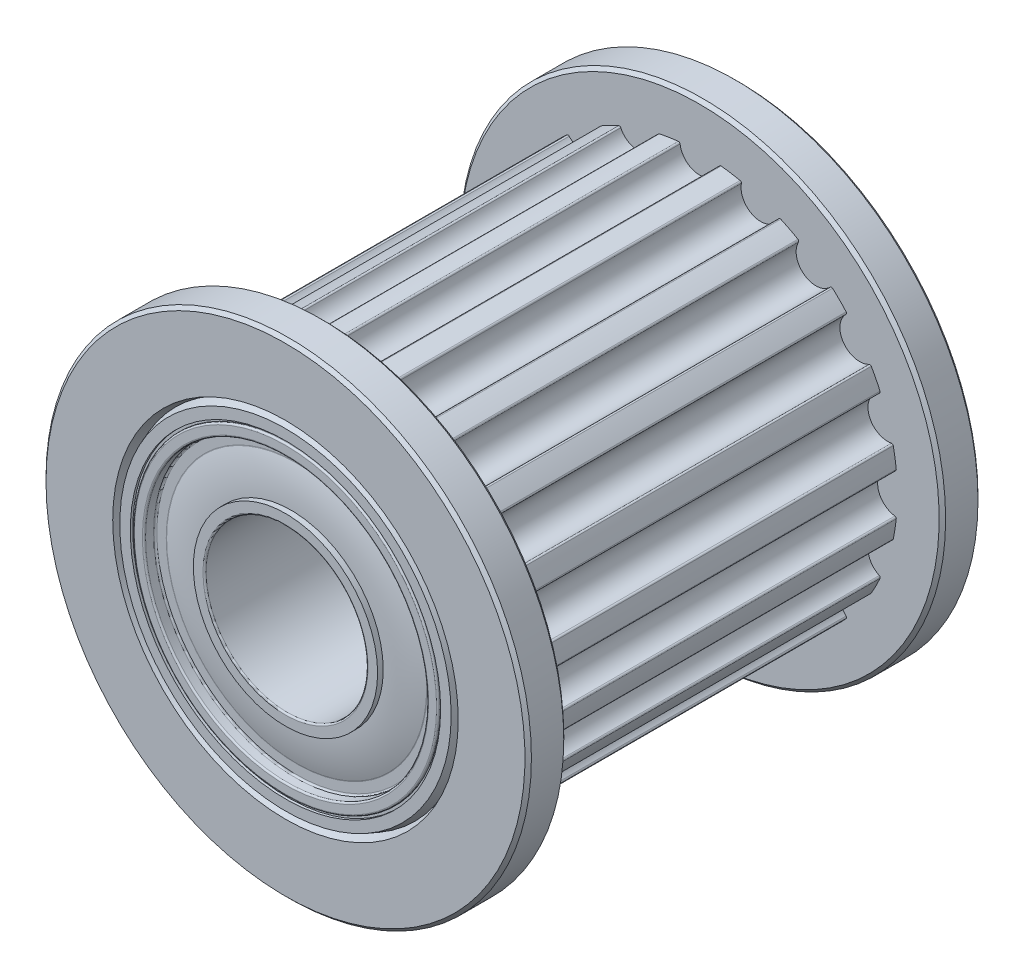
from build123d import *

# Parameters (mm, degrees)
CUT_EXTRUDE1_REACH             = 14.708
CUT_EXTRUDE1_DIRECTION_2_REACH = 14.708
FILLET1_R                      = 0.05
CIRPATTERN3_COUNT              = 20
FILLET1_OF_CIRPATTERN3_R       = 0.05
CHAMFER1_SIZE                  = 0.1
FILLET2_R                      = 0.05


with BuildPart() as part:
    # Sketch2 → Revolve1 (revolve)
    with BuildSketch(Plane(origin=(0, 0, 0), x_dir=(0, 0, -1), z_dir=(1, 0, 0))):
        with BuildLine():
            Line((7, 2.5), (0, 2.5))
            Line((0, 2.5), (0, 4.72))
            Line((0, 4.72), (7, 4.72))
            Line((7, 4.72), (7, 4.3725))
            Line((7, 4.3725), (6.6525, 4.3725))
            Line((6.6525, 4.3725), (6.6525, 4.025))
            ThreePointArc((6.6525, 4.025), (6.782578593, 3.442625053), (6.82625, 2.8475))
            Line((6.82625, 2.8475), (7, 2.8475))
            Line((7, 2.8475), (7, 2.5))
        make_face()
    revolve(axis=Axis((0, 0, 7), (0, 0, -1)))

    # Mirror1: part across plane


with BuildPart() as part_1:
    add(part.part)
    add(part.part.mirror(Plane.XY))

    # Fillet2
    fillet2_edges = [part_1.edges().sort_by_distance(p)[0] for p in [
        (0, -4.025, 6.6525),
        (0, -4.3725, 6.6525),
        (0, -4.72, 7),
        (0, -4.3725, 7),
        (0, -2.5, 7),
        (0, -2.5, -7),
        (0, -4.72, -7),
        (0, -4.025, -6.6525),
        (0, -4.3725, -7),
        (0, -2.8475, -7),
    ]]
    fillet(fillet2_edges, radius=FILLET2_R)


with BuildPart() as body_2:
    # Sketch3 → Revolve2 (revolve)
    with BuildSketch(Plane(origin=(0, 0, 0), x_dir=(0, 0, -1), z_dir=(1, 0, 0))):
        Polygon((5.8, 7.5), (7, 7.5), (7, 5.338382141), (6.7, 5.22919107), (7, 5.12), (7, 4.795), (6.925, 4.795), (6.925, 4.72), (-6.925, 4.72), (-6.925, 4.795), (-7, 4.795), (-7, 5.12), (-6.7, 5.22919107), (-7, 5.338382141), (-7, 7.5), (-5.8, 7.5), (-5.8, 6.11), (5.8, 6.11), align=None)
    revolve(axis=Axis((0, 0, 7), (0, 0, -1)))

    # Cut-Extrude1: up to this face of the body (flat: up to its plane)
    cut_extrude1_end = Plane(body_2.part.faces().sort_by_distance((0, -6.322132034, -5.8))[0])
    # Sketch4 → Cut-Extrude1 (cut, up to the picked face)
    with BuildSketch(Plane.XY, mode=Mode.PRIVATE) as cut_extrude1_sk1:
        with BuildLine():
            Line((-0.611, 6.11), (0.611, 6.11))
            ThreePointArc((0.611, 6.11), (0, 5.499), (-0.611, 6.11))
        make_face()
    cut_extrude1_tool1 = split(extrude(cut_extrude1_sk1.sketch, amount=-CUT_EXTRUDE1_REACH, mode=Mode.PRIVATE), bisect_by=cut_extrude1_end, keep=Keep.BOTH, mode=Mode.PRIVATE)
    cut_extrude1 = cut_extrude1_tool1.solids().sort_by(Axis((0, 5.850684, 0), (0, 0, -1)))[0]
    add(cut_extrude1, mode=Mode.SUBTRACT)

    # Cut-Extrude1 direction 2: up to this face of the body (flat: up to its plane)
    cut_extrude1_direction_2_end = Plane(body_2.part.faces().sort_by_distance((0, -7.287867966, 5.8))[0])
    # Sketch4 → Cut-Extrude1 direction 2 (cut, up to the picked face)
    with BuildSketch(Plane.XY, mode=Mode.PRIVATE) as cut_extrude1_direction_2_sk1:
        with BuildLine():
            Line((-0.611, 6.11), (0.611, 6.11))
            ThreePointArc((0.611, 6.11), (0, 5.499), (-0.611, 6.11))
        make_face()
    cut_extrude1_direction_2_tool1 = split(extrude(cut_extrude1_direction_2_sk1.sketch, amount=CUT_EXTRUDE1_DIRECTION_2_REACH, mode=Mode.PRIVATE), bisect_by=cut_extrude1_direction_2_end, keep=Keep.BOTH, mode=Mode.PRIVATE)
    cut_extrude1_direction_2 = cut_extrude1_direction_2_tool1.solids().sort_by(Axis((0, 5.850684, 0), (0, 0, 1)))[0]
    add(cut_extrude1_direction_2, mode=Mode.SUBTRACT)

    # Fillet1
    fillet1_edges = [body_2.edges().sort_by_distance(p)[0] for p in [
        (0.610235772, 6.07945, 0),
        (-0.610235772, 6.07945, 0),
    ]]
    fillet(fillet1_edges, radius=FILLET1_R)

    # CirPattern3: Cut-Extrude1, Cut-Extrude1 direction 2 ×20 about axis
    cirpattern3_axis = Axis((0, 0, -5.8), (0, 0, 1))
    add([cut_extrude1.rotate(cirpattern3_axis, i * 360 / CIRPATTERN3_COUNT) for i in range(1, CIRPATTERN3_COUNT)], mode=Mode.SUBTRACT)
    add([cut_extrude1_direction_2.rotate(cirpattern3_axis, i * 360 / CIRPATTERN3_COUNT) for i in range(1, CIRPATTERN3_COUNT)], mode=Mode.SUBTRACT)

    # Fillet1 of CirPattern3
    fillet1_of_cirpattern3_edges = [body_2.edges().sort_by_distance(p)[0] for p in [
        (-1.298284659, 5.970473762, 0),
        (-2.459022074, 5.593327314, 0),
        (-3.079719942, 5.277065954, 0),
        (-4.067102162, 4.559690779, 0),
        (-4.559690779, 4.067102162, 0),
        (-5.277065954, 3.079719942, 0),
        (-5.593327314, 2.459022074, 0),
        (-5.970473762, 1.298284659, 0),
        (-6.07945, 0.610235772, 0),
        (-6.07945, -0.610235772, 0),
        (-5.970473762, -1.298284659, 0),
        (-5.593327314, -2.459022074, 0),
        (-5.277065954, -3.079719942, 0),
        (-4.559690779, -4.067102162, 0),
        (-4.067102162, -4.559690779, 0),
        (-3.079719942, -5.277065954, 0),
        (-2.459022074, -5.593327314, 0),
        (-1.298284659, -5.970473762, 0),
        (-0.610235772, -6.07945, 0),
        (0.610235772, -6.07945, 0),
        (1.298284659, -5.970473762, 0),
        (2.459022074, -5.593327314, 0),
        (3.079719942, -5.277065954, 0),
        (4.067102162, -4.559690779, 0),
        (4.559690779, -4.067102162, 0),
        (5.277065954, -3.079719942, 0),
        (5.593327314, -2.459022074, 0),
        (5.970473762, -1.298284659, 0),
        (6.07945, -0.610235772, 0),
        (6.07945, 0.610235772, 0),
        (5.970473762, 1.298284659, 0),
        (5.593327314, 2.459022074, 0),
        (5.277065954, 3.079719942, 0),
        (4.559690779, 4.067102162, 0),
        (4.067102162, 4.559690779, 0),
        (3.079719942, 5.277065954, 0),
        (2.459022074, 5.593327314, 0),
        (1.298284659, 5.970473762, 0),
    ]]
    fillet(fillet1_of_cirpattern3_edges, radius=FILLET1_OF_CIRPATTERN3_R)

    # Chamfer1
    chamfer1_edges = [body_2.edges().sort_by_distance(p)[0] for p in [
        (0, -7.5, -7),
        (0, -7.5, -5.8),
        (0, -7.5, 5.8),
        (0, -7.5, 7),
    ]]
    chamfer(chamfer1_edges, length=CHAMFER1_SIZE)

    # Combine1: union part
    add(part_1.part)


solid = body_2.part
